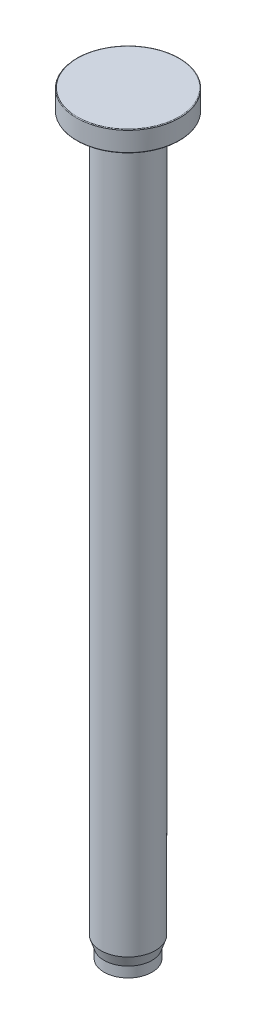
from build123d import *

# Parameters (mm, degrees)
MAINBODYS_R    = 4
MAINBODY_DEPTH = 104
HEADS_W        = 7.5
HEADS_H        = 3
HEADFILLET_R   = 0.1


with BuildPart() as part:
    # MainBodyS → MainBody (new body)
    with BuildSketch(Plane(origin=(0, 0, 0), x_dir=(1, 0, 0), z_dir=(0, 1, 0))):
        Circle(MAINBODYS_R)
    extrude(amount=-MAINBODY_DEPTH)

    # HeadS → Head (revolve)
    with BuildSketch(Plane.XY):
        with Locations((3.75, 1.5)):
            Rectangle(HEADS_W, HEADS_H)
    revolve(axis=Axis((0, 0, 0), (0, 1, 0)))

    # HeadIndentS → HeadIndent (revolve, cut)
    with BuildSketch(Plane.XY):
        with BuildLine():
            Line((4, 0), (4, 0.4))
            ThreePointArc((4, 0.4), (4.029289322, 0.470710678), (4.1, 0.5))
            Line((4.1, 0.5), (6, 0.5))
            ThreePointArc((6, 0.5), (6.023974846, 0.497083504), (6.046551241, 0.488504135))
            Line((6.046551241, 0.488504135), (6.953448759, 0.011495865))
            ThreePointArc((6.953448759, 0.011495865), (6.976025154, 0.002916496), (7, 0))
            Line((7, 0), (4, 0))
        make_face()
    revolve(axis=Axis((0, 0, 0), (0, 1, 0)), mode=Mode.SUBTRACT)

    # BottomTipS → BottomTip (revolve)
    with BuildSketch(Plane.XY):
        Polygon((4, -104), (3.5, -105.5), (3.5, -107), (0, -107), (0, -104), align=None)
    revolve(axis=Axis((0, -107, 0), (0, 1, 0)))

    # HeadFillet
    headfillet_edges = [part.edges().sort_by_distance(p)[0] for p in [
        (-7.5, 0, 0),
        (-7.5, 3, 0),
    ]]
    fillet(headfillet_edges, radius=HEADFILLET_R)


solid = part.part
